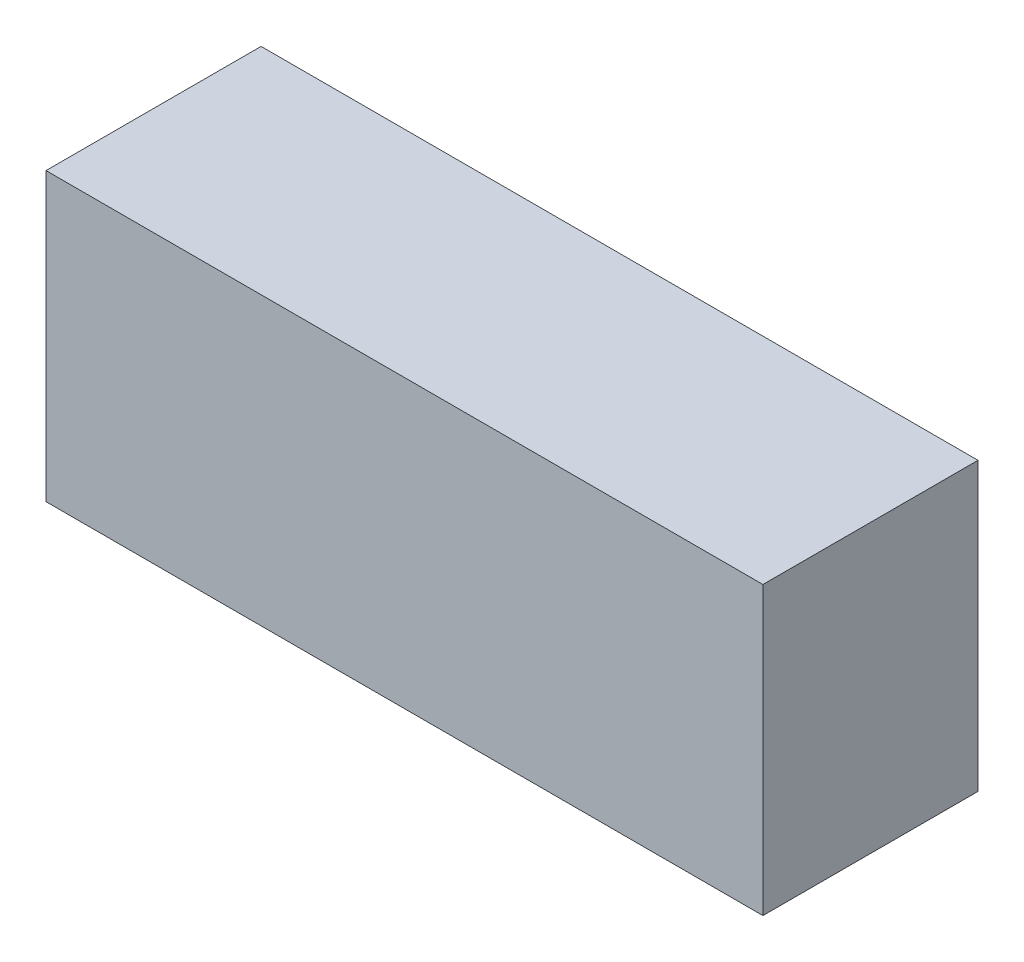
from build123d import *

# Parameters (mm, degrees)
SKETCH1_W           = 10
SKETCH1_H           = 4
BOSS_EXTRUDE1_DEPTH = 3


with BuildPart() as part:
    # Sketch1 → Boss-Extrude1 (new body)
    with BuildSketch(Plane.XY):
        with Locations((-5, -2)):
            Rectangle(SKETCH1_W, SKETCH1_H)
    extrude(amount=BOSS_EXTRUDE1_DEPTH)


solid = part.part
